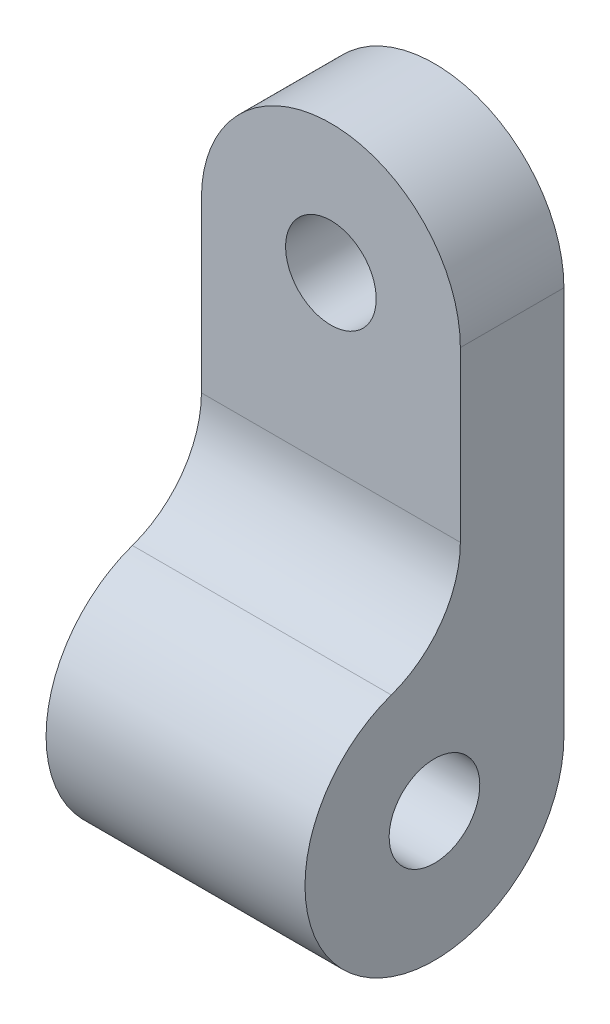
from build123d import *

# Parameters (mm, degrees)
ESBO_O1_R                = 1.75
RESSALTO_EXTRUS_O1_DEPTH = 10
ESBO_O2_W                = 6
ESBO_O2_H                = 5
ESBO_O2_R                = 1.75
CORTE_EXTRUS_O1_DEPTH    = 10


with BuildPart() as part:
    # Esboço1 → Ressalto-extrusão1 (new body)
    with BuildSketch(Plane.XY):
        with BuildLine():
            Line((-5, 0), (-5, -20))
            Line((-5, -20), (5, -20))
            Line((5, -20), (5, 0))
            ThreePointArc((5, 0), (0, 5), (-5, 0))
        make_face()
        Circle(ESBO_O1_R, mode=Mode.SUBTRACT)
    extrude(amount=RESSALTO_EXTRUS_O1_DEPTH)

    # Esboço2 → Corte-extrusão1 (cut)
    with BuildSketch(Plane.ZY.offset(5)):
        with BuildLine():
            Line((10, 0), (4, 0))
            Line((4, 0), (4, -6.514718626))
            ThreePointArc((4, -6.514718626), (4.734013676, -8.824119703), (6.666666667, -10.285954792))
            ThreePointArc((6.666666667, -10.285954792), (9.082482905, -12.113248654), (10, -15))
            Line((10, -15), (10, 0))
        make_face()
        with Locations((7, 2.5)):
            Rectangle(ESBO_O2_W, ESBO_O2_H)
        with BuildLine():
            Line((10, -20), (10, -15))
            ThreePointArc((10, -15), (8.535533906, -18.535533906), (5, -20))
            Line((5, -20), (10, -20))
        make_face()
        with BuildLine():
            ThreePointArc((5, -20), (1.464466094, -18.535533906), (0, -15))
            Line((0, -15), (0, -20))
            Line((0, -20), (5, -20))
        make_face()
        with Locations((5, -15)):
            Circle(ESBO_O2_R)
    extrude(amount=-CORTE_EXTRUS_O1_DEPTH, mode=Mode.SUBTRACT)


solid = part.part
